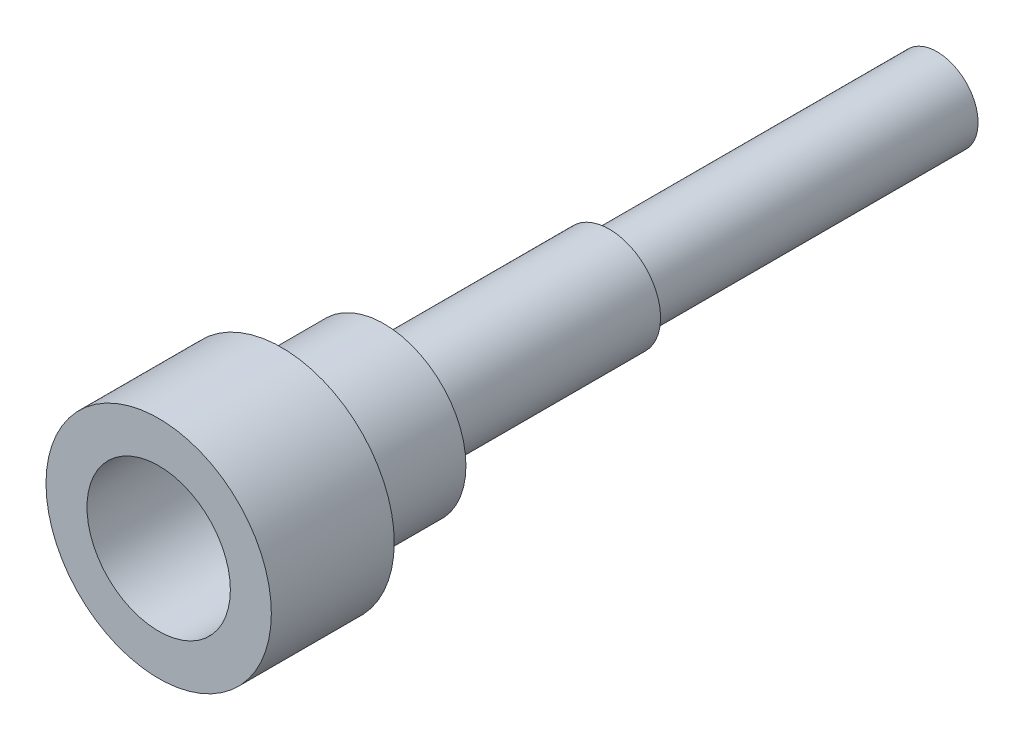
from build123d import *

# Parameters (mm, degrees)
CROQUIS1_R              = 4
SALIENTE_EXTRUIR1_DEPTH = 5
CROQUIS2_R              = 5.5
CROQUIS2_R_2            = 3.5
SALIENTE_EXTRUIR2_DEPTH = 6
CROQUIS3_R              = 2.5
SALIENTE_EXTRUIR3_DEPTH = 11
CROQUIS4_R              = 2
SALIENTE_EXTRUIR4_DEPTH = 16
CROQUIS5_R              = 0.75
CORTAR_EXTRUIR1_DEPTH   = 6.5


with BuildPart() as part:
    # Croquis1 → Saliente-Extruir1 (new body)
    with BuildSketch(Plane.XY):
        Circle(CROQUIS1_R)
    extrude(amount=SALIENTE_EXTRUIR1_DEPTH)

    # Croquis2 → Saliente-Extruir2 (add)
    with BuildSketch(Plane.XY.offset(5)):
        Circle(CROQUIS2_R)
        Circle(CROQUIS2_R_2, mode=Mode.SUBTRACT)
    extrude(amount=SALIENTE_EXTRUIR2_DEPTH)

    # Croquis3 → Saliente-Extruir3 (add)
    with BuildSketch(Plane(origin=(0, 0, 0), x_dir=(-1, 0, 0), z_dir=(0, 0, -1))):
        Circle(CROQUIS3_R)
    extrude(amount=SALIENTE_EXTRUIR3_DEPTH)

    # Croquis4 → Saliente-Extruir4 (add)
    with BuildSketch(Plane(origin=(0, 0, -11), x_dir=(-1, 0, 0), z_dir=(0, 0, -1))):
        Circle(CROQUIS4_R)
    extrude(amount=SALIENTE_EXTRUIR4_DEPTH)

    # Croquis5 → Cortar-Extruir1 (cut, through all)
    with BuildSketch(Plane(origin=(0, 0, 0), x_dir=(1, 0, 0), z_dir=(0, 1, 0))):
        with Locations((0, 9.5)):
            Circle(CROQUIS5_R)
    extrude(amount=-CORTAR_EXTRUIR1_DEPTH, mode=Mode.SUBTRACT)


solid = part.part
